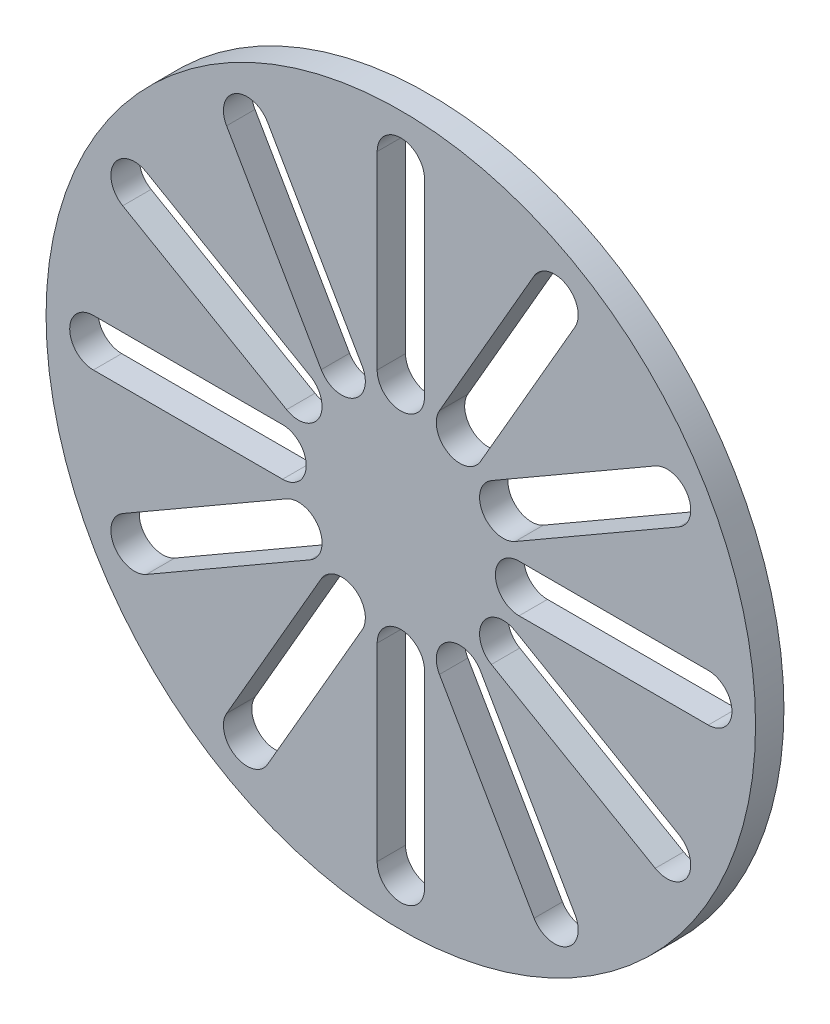
from build123d import *

# Parameters (mm, degrees)
SKETCH1_R           = 95.25
BOSS_EXTRUDE1_DEPTH = 7.62


with BuildPart() as part:
    # Sketch1 → Boss-Extrude1 (new body)
    with BuildSketch(Plane.XY):
        Circle(SKETCH1_R)
        with BuildLine():
            Line((-6.35, 82.55), (-6.35, 31.75))
            ThreePointArc((-6.35, 31.75), (0, 25.4), (6.35, 31.75))
            Line((6.35, 31.75), (6.35, 82.55))
            ThreePointArc((6.35, 82.55), (0, 88.9), (-6.35, 82.55))
        make_face(mode=Mode.SUBTRACT)
        with BuildLine():
            Line((46.774261314, 68.315397082), (21.374261314, 24.32130657))
            ThreePointArc((21.374261314, 24.32130657), (12.7, 21.997045256), (10.375738686, 30.67130657))
            Line((10.375738686, 30.67130657), (35.775738686, 74.665397082))
            ThreePointArc((35.775738686, 74.665397082), (44.45, 76.989658396), (46.774261314, 68.315397082))
        make_face(mode=Mode.SUBTRACT)
        with BuildLine():
            Line((74.665397082, 35.775738686), (30.67130657, 10.375738686))
            ThreePointArc((30.67130657, 10.375738686), (21.997045256, 12.7), (24.32130657, 21.374261314))
            Line((24.32130657, 21.374261314), (68.315397082, 46.774261314))
            ThreePointArc((68.315397082, 46.774261314), (76.989658396, 44.45), (74.665397082, 35.775738686))
        make_face(mode=Mode.SUBTRACT)
        with BuildLine():
            Line((82.55, -6.35), (31.75, -6.35))
            ThreePointArc((31.75, -6.35), (25.4, 0), (31.75, 6.35))
            Line((31.75, 6.35), (82.55, 6.35))
            ThreePointArc((82.55, 6.35), (88.9, 0), (82.55, -6.35))
        make_face(mode=Mode.SUBTRACT)
        with BuildLine():
            Line((68.315397082, -46.774261314), (24.32130657, -21.374261314))
            ThreePointArc((24.32130657, -21.374261314), (21.997045256, -12.7), (30.67130657, -10.375738686))
            Line((30.67130657, -10.375738686), (74.665397082, -35.775738686))
            ThreePointArc((74.665397082, -35.775738686), (76.989658396, -44.45), (68.315397082, -46.774261314))
        make_face(mode=Mode.SUBTRACT)
        with BuildLine():
            Line((35.775738686, -74.665397082), (10.375738686, -30.67130657))
            ThreePointArc((10.375738686, -30.67130657), (12.7, -21.997045256), (21.374261314, -24.32130657))
            Line((21.374261314, -24.32130657), (46.774261314, -68.315397082))
            ThreePointArc((46.774261314, -68.315397082), (44.45, -76.989658396), (35.775738686, -74.665397082))
        make_face(mode=Mode.SUBTRACT)
        with BuildLine():
            Line((-6.35, -82.55), (-6.35, -31.75))
            ThreePointArc((-6.35, -31.75), (0, -25.4), (6.35, -31.75))
            Line((6.35, -31.75), (6.35, -82.55))
            ThreePointArc((6.35, -82.55), (0, -88.9), (-6.35, -82.55))
        make_face(mode=Mode.SUBTRACT)
        with BuildLine():
            Line((-46.774261314, -68.315397082), (-21.374261314, -24.32130657))
            ThreePointArc((-21.374261314, -24.32130657), (-12.7, -21.997045256), (-10.375738686, -30.67130657))
            Line((-10.375738686, -30.67130657), (-35.775738686, -74.665397082))
            ThreePointArc((-35.775738686, -74.665397082), (-44.45, -76.989658396), (-46.774261314, -68.315397082))
        make_face(mode=Mode.SUBTRACT)
        with BuildLine():
            Line((-74.665397082, -35.775738686), (-30.67130657, -10.375738686))
            ThreePointArc((-30.67130657, -10.375738686), (-21.997045256, -12.7), (-24.32130657, -21.374261314))
            Line((-24.32130657, -21.374261314), (-68.315397082, -46.774261314))
            ThreePointArc((-68.315397082, -46.774261314), (-76.989658396, -44.45), (-74.665397082, -35.775738686))
        make_face(mode=Mode.SUBTRACT)
        with BuildLine():
            Line((-82.55, 6.35), (-31.75, 6.35))
            ThreePointArc((-31.75, 6.35), (-25.4, 0), (-31.75, -6.35))
            Line((-31.75, -6.35), (-82.55, -6.35))
            ThreePointArc((-82.55, -6.35), (-88.9, 0), (-82.55, 6.35))
        make_face(mode=Mode.SUBTRACT)
        with BuildLine():
            Line((-68.315397082, 46.774261314), (-24.32130657, 21.374261314))
            ThreePointArc((-24.32130657, 21.374261314), (-21.997045256, 12.7), (-30.67130657, 10.375738686))
            Line((-30.67130657, 10.375738686), (-74.665397082, 35.775738686))
            ThreePointArc((-74.665397082, 35.775738686), (-76.989658396, 44.45), (-68.315397082, 46.774261314))
        make_face(mode=Mode.SUBTRACT)
        with BuildLine():
            Line((-35.775738686, 74.665397082), (-10.375738686, 30.67130657))
            ThreePointArc((-10.375738686, 30.67130657), (-12.7, 21.997045256), (-21.374261314, 24.32130657))
            Line((-21.374261314, 24.32130657), (-46.774261314, 68.315397082))
            ThreePointArc((-46.774261314, 68.315397082), (-44.45, 76.989658396), (-35.775738686, 74.665397082))
        make_face(mode=Mode.SUBTRACT)
    extrude(amount=BOSS_EXTRUDE1_DEPTH)


solid = part.part
